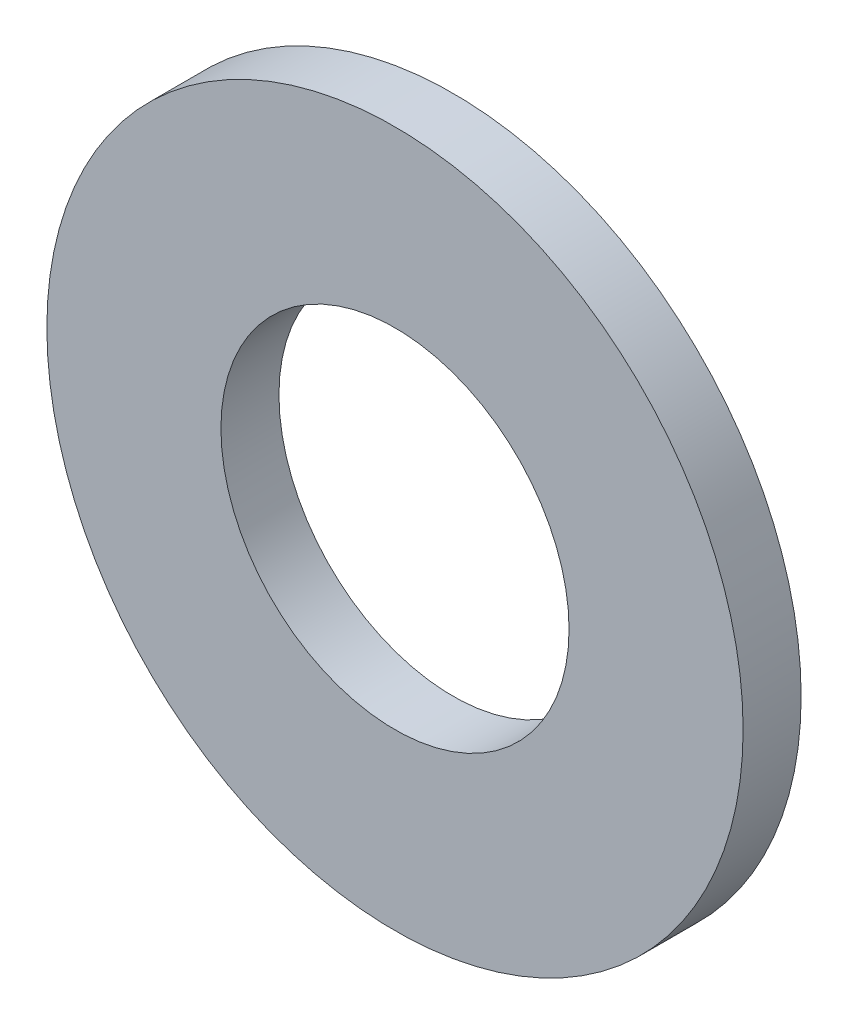
from build123d import *

# Parameters (mm, degrees)
SKETCH1_R           = 9.525
SKETCH1_R_2         = 4.7625
BOSS_EXTRUDE1_DEPTH = 1.5875


with BuildPart() as part:
    # Sketch1 → Boss-Extrude1 (new body)
    with BuildSketch(Plane.XY):
        Circle(SKETCH1_R)
        Circle(SKETCH1_R_2, mode=Mode.SUBTRACT)
    extrude(amount=BOSS_EXTRUDE1_DEPTH)


solid = part.part
